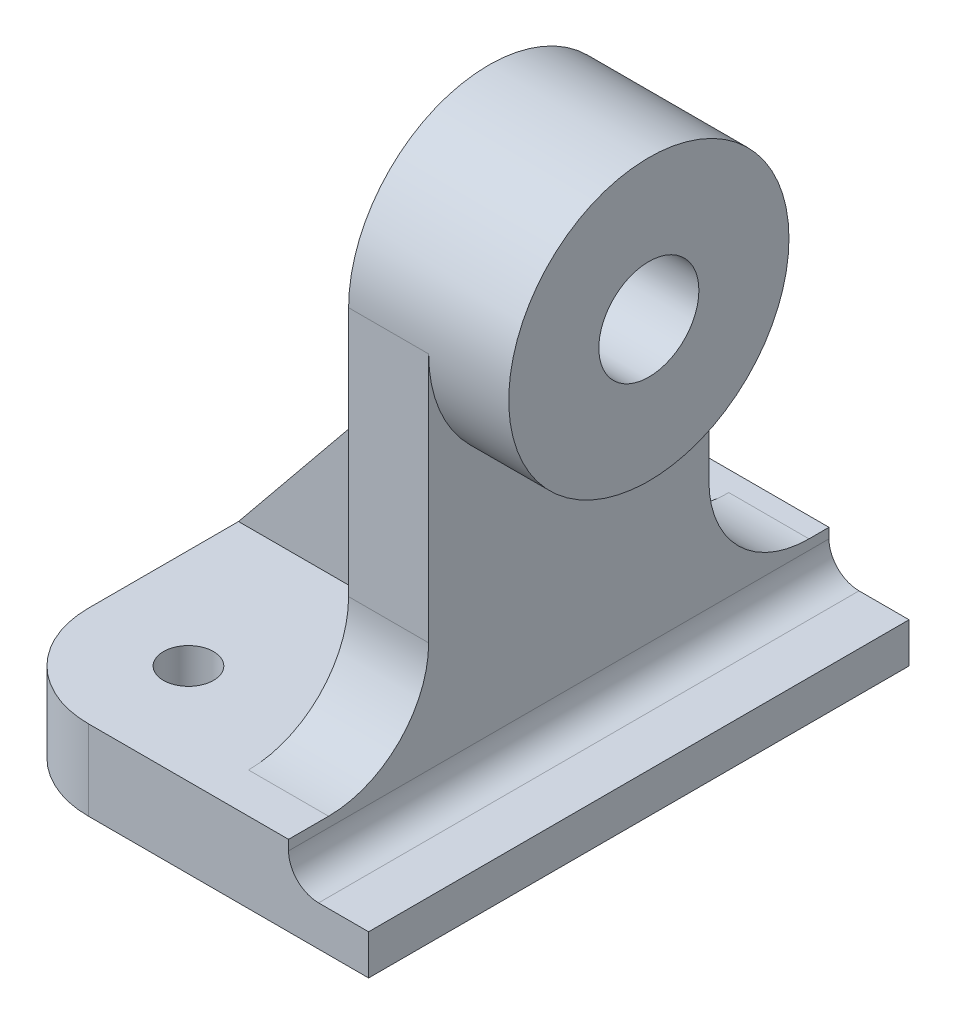
from build123d import *

# Parameters (mm, degrees)
IZIM1_W                     = 38
IZIM1_H                     = 54
Y_KSEKLIK_EKSTR_ZYON1_DEPTH = 8
IZIM2_W                     = 8
IZIM2_H                     = 4
KES_EKSTR_ZYON1_DEPTH       = 67.513156593
RADYUS1_R                   = 3
RADYUS2_R                   = 10
IZIM4_R                     = 2.5
KES_EKSTR_ZYON2_DEPTH       = 67.513156593
Y_KSEKLIK_EKSTR_ZYON2_DEPTH = 8
RADYUS3_R                   = 10
IZIM6_R                     = 14
Y_KSEKLIK_EKSTR_ZYON3_DEPTH = 8
IZIM7_R                     = 5
KES_EKSTR_ZYON3_DEPTH       = 88.229582138
FEDER2_REACH                = 76.007
IZIM8_WALL_W                = 184.841662432
IZIM8_WALL_H                = 6


with BuildPart() as part:
    # Çizim1 → Yükseklik-Ekstrüzyon1 (new body)
    with BuildSketch(Plane(origin=(0, 0, 0), x_dir=(1, 0, 0), z_dir=(0, 1, 0))):
        with Locations((-19, 27)):
            Rectangle(IZIM1_W, IZIM1_H)
    extrude(amount=Y_KSEKLIK_EKSTR_ZYON1_DEPTH)

    # Çizim2 → Kes-Ekstrüzyon1 (cut, through all)
    with BuildSketch(Plane.XY):
        with Locations((-4, 6)):
            Rectangle(IZIM2_W, IZIM2_H)
    extrude(amount=-KES_EKSTR_ZYON1_DEPTH, mode=Mode.SUBTRACT)

    # Radyus1
    radyus1_edges = [part.edges().sort_by_distance(p)[0] for p in [
        (-8, 4, -27),
    ]]
    fillet(radyus1_edges, radius=RADYUS1_R)

    # Radyus2
    radyus2_edges = [part.edges().sort_by_distance(p)[0] for p in [
        (-38, 4, 0),
        (-38, 4, -54),
    ]]
    fillet(radyus2_edges, radius=RADYUS2_R)

    # Çizim4 → Kes-Ekstrüzyon2 (cut, through all)
    with BuildSketch(Plane(origin=(0, 8, 0), x_dir=(1, 0, 0), z_dir=(0, 1, 0))):
        with Locations(Location((-28, 44, 0), (0, 0, 270))):
            Circle(IZIM4_R)
        with Locations(Location((-28, 10, 0), (0, 0, 270))):
            Circle(IZIM4_R)
    extrude(amount=-KES_EKSTR_ZYON2_DEPTH, mode=Mode.SUBTRACT)

    # Çizim5 → Yükseklik-Ekstrüzyon2 (add)
    with BuildSketch(Plane(origin=(-8, 0, 0), x_dir=(0, 0, -1), z_dir=(1, 0, 0))):
        with BuildLine():
            Line((14, 43), (14, 8))
            Line((14, 8), (42, 8))
            Line((42, 8), (42, 43))
            ThreePointArc((42, 43), (28, 57), (14, 43))
        make_face()
    extrude(amount=-Y_KSEKLIK_EKSTR_ZYON2_DEPTH)

    # Radyus3
    radyus3_edges = [part.edges().sort_by_distance(p)[0] for p in [
        (-12, 8, -42),
        (-12, 8, -14),
    ]]
    fillet(radyus3_edges, radius=RADYUS3_R)

    # Çizim6 → Yükseklik-Ekstrüzyon3 (add)
    with BuildSketch(Plane(origin=(-8, 0, 0), x_dir=(0, 0, -1), z_dir=(1, 0, 0))):
        with Locations((28, 43)):
            Circle(IZIM6_R)
    extrude(amount=Y_KSEKLIK_EKSTR_ZYON3_DEPTH)

    # Çizim7 → Kes-Ekstrüzyon3 (cut, through all)
    with BuildSketch(Plane(origin=(0, 0, 0), x_dir=(0, 0, -1), z_dir=(1, 0, 0))):
        with Locations((28, 43)):
            Circle(IZIM7_R)
    extrude(amount=-KES_EKSTR_ZYON3_DEPTH, mode=Mode.SUBTRACT)

    # Çizim8 wall → Feder2 (add, up to next)
    with BuildSketch(Plane(origin=(-27, 21.5, -28), x_dir=(0.631672951162, 0.775234985517, 0), z_dir=(-0.775234985517, 0.631672951162, 0)), mode=Mode.PRIVATE) as feder2_sk1:
        Rectangle(IZIM8_WALL_W, IZIM8_WALL_H)
    feder2_tool1 = extrude(feder2_sk1.sketch, amount=-FEDER2_REACH, mode=Mode.PRIVATE) - part.part
    add(feder2_tool1.solids().sort_by_distance((-27, 21.5, -28))[0])


solid = part.part
